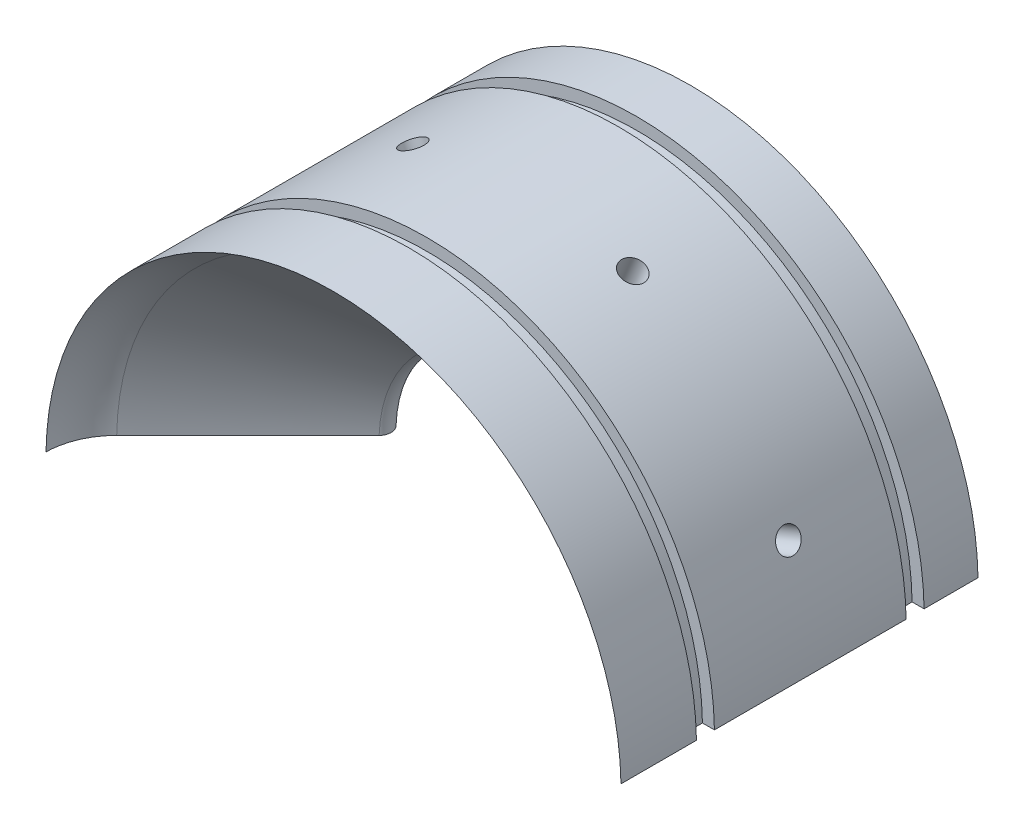
from build123d import *

# Parameters (mm, degrees)
SKETCH2_W               = 316.892468242
SKETCH2_H               = 286.660554426
CUT_EXTRUDE1_DEPTH      = 1.27
CUT_EXTRUDE1_DEPTH_BACK = 77.2
SKETCH3_R               = 3.175
CUT_EXTRUDE2_DEPTH      = 19.05
CIRPATTERN1_COUNT       = 8


with BuildPart() as part:
    # Sketch1 → Revolve1 (revolve)
    with BuildSketch(Plane(origin=(0, 0, 0), x_dir=(0, 0, -1), z_dir=(1, 0, 0))):
        with BuildLine():
            ThreePointArc((-50.167050753, 76.2), (-43.047460251, 74.691369941), (-37.013141195, 70.623013134))
            Line((-37.013141195, 70.623013134), (-2.24506403, 35.85493597))
            ThreePointArc((-2.24506403, 35.85493597), (0, 34.925), (2.24506403, 35.85493597))
            ThreePointArc((2.24506403, 35.85493597), (21.675043526, 50.270960023), (44.45, 58.434734291))
            Line((44.45, 58.434734291), (44.45, 76.2))
            Line((44.45, 76.2), (30.1625, 76.2))
            Line((30.1625, 76.2), (30.1625, 73.025))
            Line((30.1625, 73.025), (25.4, 73.025))
            Line((25.4, 73.025), (25.4, 76.2))
            Line((25.4, 76.2), (-25.4, 76.2))
            Line((-25.4, 76.2), (-25.4, 73.025))
            Line((-25.4, 73.025), (-30.1625, 73.025))
            Line((-30.1625, 73.025), (-30.1625, 76.2))
            Line((-30.1625, 76.2), (-50.167050753, 76.2))
        make_face()
    revolve(axis=Axis((0, 0, 0), (0, 0, 1)))

    # Sketch2 → Cut-Extrude1 (cut, two sides)
    with BuildSketch(Plane(origin=(0, 0, 0), x_dir=(1, 0, 0), z_dir=(0, 1, 0))) as cut_extrude1_sk:
        Rectangle(SKETCH2_W, SKETCH2_H)
    extrude(amount=CUT_EXTRUDE1_DEPTH, mode=Mode.SUBTRACT)
    extrude(cut_extrude1_sk.sketch, amount=-CUT_EXTRUDE1_DEPTH_BACK, mode=Mode.SUBTRACT)

    # Sketch3 → Cut-Extrude2 (cut)
    with BuildSketch(Plane(origin=(29.160477546, 70.399620377, 0), x_dir=(0, 0, -1), z_dir=(0.382683432, 0.923879533, 0))):
        Circle(SKETCH3_R)
    cut_extrude2 = extrude(amount=-CUT_EXTRUDE2_DEPTH, mode=Mode.SUBTRACT)

    # CirPattern1: Cut-Extrude2 ×8 about axis
    cirpattern1_axis = Axis((0, 0, 0), (0, 0, 1))
    for i in range(1, CIRPATTERN1_COUNT):
        add(cut_extrude2.rotate(cirpattern1_axis, i * 360 / CIRPATTERN1_COUNT), mode=Mode.SUBTRACT)


solid = part.part
